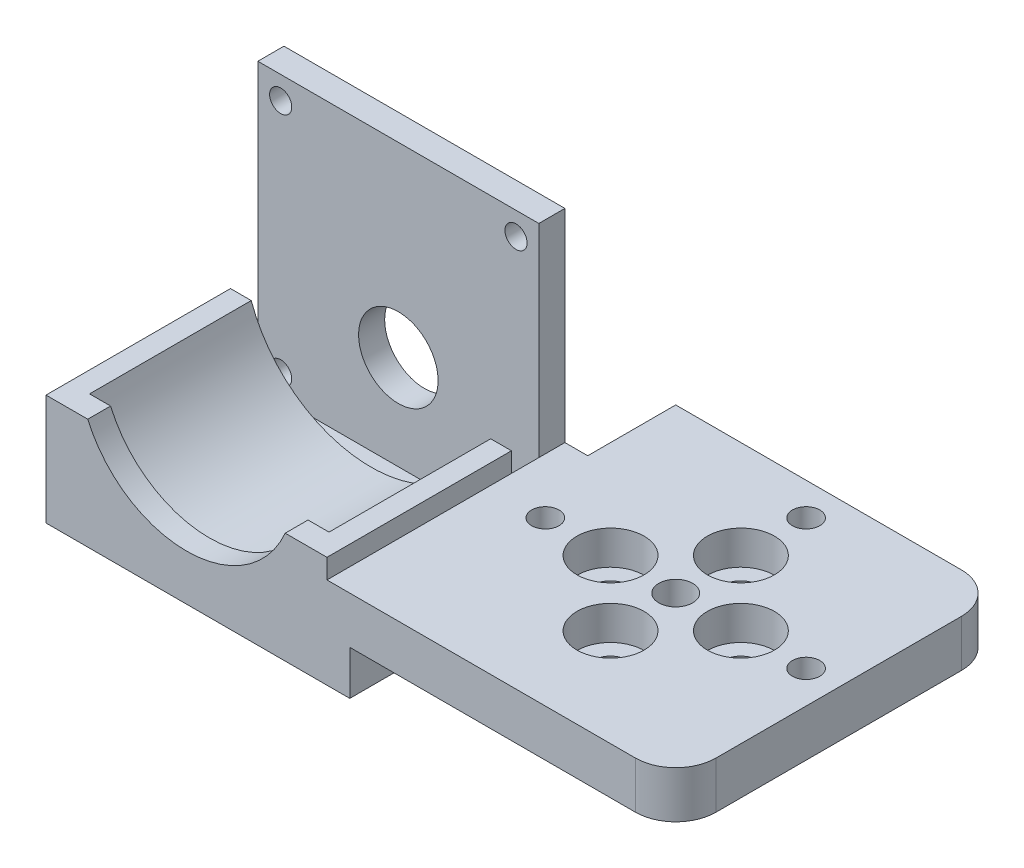
from build123d import *

# Parameters (mm, degrees)
SKETCH_2_W          = 50
SKETCH_2_H          = 50
SKETCH_2_R          = 2.6
EXTRUDE_1_DEPTH     = 2
SKETCH_3_W          = 50
SKETCH_3_H          = 50
SKETCH_3_R          = 5.15
SKETCH_3_R_2        = 2.6
EXTRUDE_2_DEPTH     = 5.2
SKETCH_4_R          = 2.1
CUT_EXTRUDE_1_DEPTH = 10
CUT_EXTRUDE_2_DEPTH = 3.5
FILLET_1_R          = 6.17
FILLET_2_R          = 6.17
SKETCH_7_W          = 43.1
SKETCH_7_H          = 43.1
SKETCH_7_R          = 6.1
SKETCH_7_R_2        = 1.7
EXTRUDE_3_DEPTH     = 4
EXTRUDE_4_DEPTH     = 29
EXTRUDE_5_DEPTH     = 3.5
SKETCH_10_W         = 3.5
SKETCH_10_H         = 11.99
EXTRUDE_6_DEPTH     = 36.5
SKETCH_11_W         = 43.1
SKETCH_11_H         = 43.1
CUT_EXTRUDE_3_DEPTH = 4.2
SKETCH_12_W         = 46.6
SKETCH_12_H         = 36.5
EXTRUDE_7_DEPTH     = 2
SKETCH_13_R         = 1.7
CUT_EXTRUDE_4_DEPTH = 12


with BuildPart() as part:
    # 스케치2 → 보스-돌출1 (new body)
    with BuildSketch(Plane(origin=(0, 0, 0), x_dir=(1, 0, 0), z_dir=(0, 1, 0))):
        Rectangle(SKETCH_2_W, SKETCH_2_H)
        Circle(SKETCH_2_R, mode=Mode.SUBTRACT)
        with Locations((10, 0)):
            Circle(SKETCH_2_R, mode=Mode.SUBTRACT)
        with Locations((0, -10)):
            Circle(SKETCH_2_R, mode=Mode.SUBTRACT)
        with Locations((-10, 0)):
            Circle(SKETCH_2_R, mode=Mode.SUBTRACT)
        with Locations((0, 10)):
            Circle(SKETCH_2_R, mode=Mode.SUBTRACT)
    extrude(amount=EXTRUDE_1_DEPTH)

    # 스케치3 → 보스-돌출2 (add)
    with BuildSketch(Plane(origin=(0, 2, 0), x_dir=(1, 0, 0), z_dir=(0, 1, 0))):
        Rectangle(SKETCH_3_W, SKETCH_3_H)
        with Locations((0, -10)):
            Circle(SKETCH_3_R, mode=Mode.SUBTRACT)
        with Locations((-10, 0)):
            Circle(SKETCH_3_R, mode=Mode.SUBTRACT)
        Circle(SKETCH_3_R_2, mode=Mode.SUBTRACT)
        with Locations((10, 0)):
            Circle(SKETCH_3_R, mode=Mode.SUBTRACT)
        with Locations((0, 10)):
            Circle(SKETCH_3_R, mode=Mode.SUBTRACT)
    extrude(amount=EXTRUDE_2_DEPTH)

    # 스케치4 → 컷-돌출1 (cut)
    with BuildSketch(Plane(origin=(0, 7.2, 0), x_dir=(1, 0, 0), z_dir=(0, 1, 0))):
        with Locations((20, 0)):
            Circle(SKETCH_4_R)
        with Locations((0, 20)):
            Circle(SKETCH_4_R)
        with Locations((-20, 0)):
            Circle(SKETCH_4_R)
    extrude(amount=-CUT_EXTRUDE_1_DEPTH, mode=Mode.SUBTRACT)

    # 스케치6 → 컷-돌출2 (cut)
    with BuildSketch(Plane.XZ):
        Polygon((-16.45, -2.049593456), (-16.45, 2.049593456), (-20, 4.099186911), (-23.55, 2.049593456), (-23.55, -2.049593456), (-20, -4.099186911), align=None)
        Polygon((2.049593456, -16.45), (-2.049593456, -16.45), (-4.099186911, -20), (-2.049593456, -23.55), (2.049593456, -23.55), (4.099186911, -20), align=None)
        Polygon((16.45, 2.049593456), (16.45, -2.049593456), (20, -4.099186911), (23.55, -2.049593456), (23.55, 2.049593456), (20, 4.099186911), align=None)
    extrude(amount=-CUT_EXTRUDE_2_DEPTH, mode=Mode.SUBTRACT)

    # 필렛1
    fillet_1_edges = [part.edges().sort_by_distance(p)[0] for p in [
        (25, 3.6, -25),
    ]]
    fillet(fillet_1_edges, radius=FILLET_1_R)

    # 필렛2
    fillet_2_edges = [part.edges().sort_by_distance(p)[0] for p in [
        (25, 3.6, 25),
    ]]
    fillet(fillet_2_edges, radius=FILLET_2_R)



with BuildPart() as body_2:
    # 스케치7 → 보스-돌출3 (new body)
    with BuildSketch(Plane(origin=(0, 0, -11.5), x_dir=(-1, 0, 0), z_dir=(0, 0, -1))):
        with Locations((50.05, 16.76)):
            Rectangle(SKETCH_7_W, SKETCH_7_H)
        with Locations((50.05, 9.71)):
            Circle(SKETCH_7_R, mode=Mode.SUBTRACT)
        with Locations((68.1, 34.81)):
            Circle(SKETCH_7_R_2, mode=Mode.SUBTRACT)
        with Locations((68.1, -1.29)):
            Circle(SKETCH_7_R_2, mode=Mode.SUBTRACT)
        with Locations((32, -1.29)):
            Circle(SKETCH_7_R_2, mode=Mode.SUBTRACT)
        with Locations((32, 34.81)):
            Circle(SKETCH_7_R_2, mode=Mode.SUBTRACT)
    extrude(amount=-EXTRUDE_3_DEPTH)

    # 스케치8 → 보스-돌출4 (add)
    with BuildSketch(Plane.XY.offset(-7.5)):
        with BuildLine():
            Line((-71.6, 10.21), (-68.417022078, 10.21))
            ThreePointArc((-68.417022078, 10.21), (-50.05, -2.74), (-31.682977922, 10.21))
            Line((-31.682977922, 10.21), (-28.5, 10.21))
            Line((-28.5, 10.21), (-28.5, -4.79))
            Line((-28.5, -4.79), (-71.6, -4.79))
            Line((-71.6, -4.79), (-71.6, 10.21))
        make_face()
    extrude(amount=EXTRUDE_4_DEPTH)

    # 스케치9 → 보스-돌출5 (add)
    with BuildSketch(Plane.XY.offset(21.5)):
        with BuildLine():
            Line((-34.905776679, 10.21), (-28.5, 10.21))
            Line((-28.5, 10.21), (-28.5, -4.79))
            Line((-28.5, -4.79), (-71.6, -4.79))
            Line((-71.6, -4.79), (-71.6, 10.21))
            Line((-71.6, 10.21), (-65.194223321, 10.21))
            ThreePointArc((-65.194223321, 10.21), (-50.05, 0.26), (-34.905776679, 10.21))
        make_face()
    extrude(amount=EXTRUDE_5_DEPTH)


with BuildPart() as part_1:
    add(part.part)

    add(body_2.part)  # 보스-돌출6 merges body 2
    # 스케치10 → 보스-돌출6 (add)
    with BuildSketch(Plane.XY.offset(25)):
        with Locations((-26.75, 1.205)):
            Rectangle(SKETCH_10_W, SKETCH_10_H)
    extrude(amount=-EXTRUDE_6_DEPTH)

    # 스케치11 → 컷-돌출3 (cut)
    with BuildSketch(Plane.XY.offset(-7.5)):
        with Locations((-50.05, 16.76)):
            Rectangle(SKETCH_11_W, SKETCH_11_H)
    extrude(amount=CUT_EXTRUDE_3_DEPTH, mode=Mode.SUBTRACT)

    # 스케치12 → 보스-돌출7 (add)
    with BuildSketch(Plane.XZ.offset(4.79)):
        with Locations((-48.3, 6.75)):
            Rectangle(SKETCH_12_W, SKETCH_12_H)
    extrude(amount=EXTRUDE_7_DEPTH)

    # 스케치13 → 컷-돌출4 (cut)
    with BuildSketch(Plane(origin=(0, 0, -11.5), x_dir=(-1, 0, 0), z_dir=(0, 0, -1))):
        with Locations((68.1, 34.81)):
            Circle(SKETCH_13_R)
        with Locations((68.1, -1.29)):
            Circle(SKETCH_13_R)
        with Locations((32, -1.29)):
            Circle(SKETCH_13_R)
        with Locations((32, 34.81)):
            Circle(SKETCH_13_R)
    extrude(amount=-CUT_EXTRUDE_4_DEPTH, mode=Mode.SUBTRACT)


solid = part_1.part
